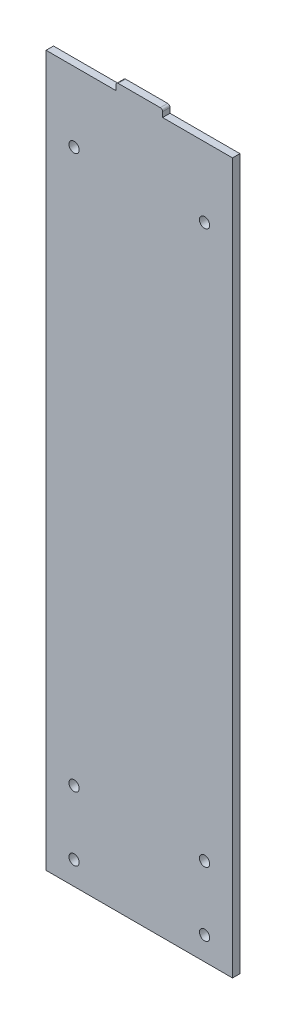
from build123d import *

# Parameters (mm, degrees)
SKETCH1_W           = 80
SKETCH1_H           = 304.8
BOSS_EXTRUDE1_DEPTH = 3.175
SKETCH2_R           = 2.2
CUT_EXTRUDE1_DEPTH  = 4.175
SKETCH3_W           = 20
SKETCH3_H           = 3.175
BOSS_EXTRUDE2_DEPTH = 3.175
FILLET1_R           = 1


with BuildPart() as part:
    # Sketch1 → Boss-Extrude1 (new body)
    with BuildSketch(Plane.XY):
        Rectangle(SKETCH1_W, SKETCH1_H)
    extrude(amount=BOSS_EXTRUDE1_DEPTH)

    # Sketch2 → Cut-Extrude1 (cut, through all)
    with BuildSketch(Plane.XY.offset(3.175)):
        with Locations((-28, -114.9)):
            Circle(SKETCH2_R)
        with Locations((28, -114.9)):
            Circle(SKETCH2_R)
        with Locations((28, -142.4)):
            Circle(SKETCH2_R)
        with Locations((-28, -142.4)):
            Circle(SKETCH2_R)
        with Locations((-28, 122.4)):
            Circle(SKETCH2_R)
        with Locations((28, 122.4)):
            Circle(SKETCH2_R)
    extrude(amount=-CUT_EXTRUDE1_DEPTH, mode=Mode.SUBTRACT)

    # Sketch3 → Boss-Extrude2 (add)
    with BuildSketch(Plane(origin=(0, 152.4, 0), x_dir=(1, 0, 0), z_dir=(0, 1, 0))):
        with Locations((0, -1.5875)):
            Rectangle(SKETCH3_W, SKETCH3_H)
    extrude(amount=BOSS_EXTRUDE2_DEPTH)

    # Fillet1
    fillet1_edges = [part.edges().sort_by_distance(p)[0] for p in [
        (10, 155.575, 1.5875),
        (-10, 155.575, 1.5875),
    ]]
    fillet(fillet1_edges, radius=FILLET1_R)


solid = part.part
